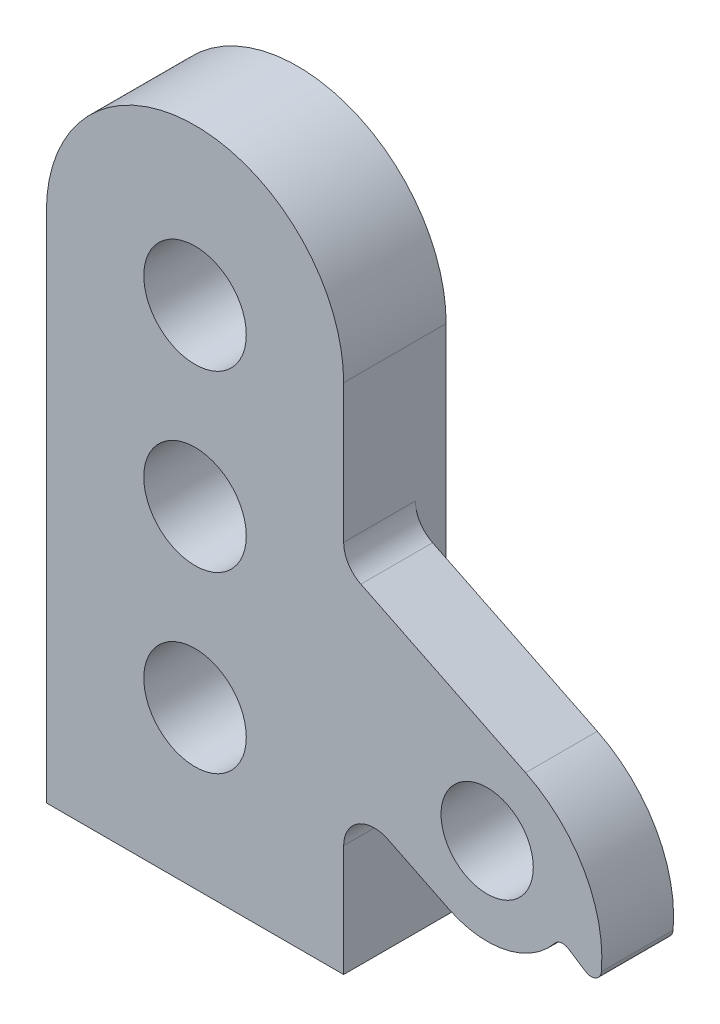
from build123d import *

# Parameters (mm, degrees)
ESQUISSE1_R             = 5
ESQUISSE1_R_2           = 4.5
BOSS_EXTRU_1_DEPTH      = 7
ESQUISSE4_R             = 5
BOSS_EXTRU_3_DEPTH      = 3
ESQUISSE5_W             = 29
ESQUISSE5_H             = 7
BOSS_EXTRU_4_DEPTH      = 8
ESQUISSE6_R             = 3
ENL_V_MAT_EXTRU_1_DEPTH = 65.5
ESQUISSE8_R             = 5
ENL_V_MAT_EXTRU_2_DEPTH = 19


with BuildPart() as part:
    # Esquisse1 → Boss.-Extru.1 (new body)
    with BuildSketch(Plane.XY):
        with BuildLine():
            Line((-14.5, -25), (14.5, -25))
            Line((14.5, -25), (14.5, -14.109086144))
            ThreePointArc((14.5, -14.109086144), (15.91383086, -11.562702933), (18.822711639, -11.416423165))
            Line((18.822711639, -11.416423165), (24.752317023, -14.329211775))
            ThreePointArc((24.752317023, -14.329211775), (30.322333643, -15.002355093), (35.098387692, -12.05829076))
            ThreePointArc((35.098387692, -12.05829076), (35.719225888, -11.700832999), (36.419839787, -11.850353167))
            Line((36.419839787, -11.850353167), (38.096489271, -12.940695548))
            ThreePointArc((38.096489271, -12.940695548), (39.079315926, -13.001513562), (39.637771245, -12.190480443))
            ThreePointArc((39.637771245, -12.190480443), (37.976265411, -4.485178535), (32.247682977, 0.929211775))
            Line((32.247682977, 0.929211775), (16.177288361, 8.823440709))
            ThreePointArc((16.177288361, 8.823440709), (14.953616789, 9.929934548), (14.5, 11.516103688))
            Line((14.5, 11.516103688), (14.5, 25))
            ThreePointArc((14.5, 25), (0, 39.5), (-14.5, 25))
            Line((-14.5, 25), (-14.5, -25))
        make_face()
        with Locations((0, 7.3)):
            Circle(ESQUISSE1_R, mode=Mode.SUBTRACT)
        with Locations((28.5, -6.7)):
            Circle(ESQUISSE1_R_2, mode=Mode.SUBTRACT)
    extrude(amount=BOSS_EXTRU_1_DEPTH)

    # Esquisse4 → Boss.-Extru.3 (add)
    with BuildSketch(Plane(origin=(0, 0, 0), x_dir=(-1, 0, 0), z_dir=(0, 0, -1))):
        with BuildLine():
            Line((14.5, 25), (14.5, -25))
            Line((14.5, -25), (-14.5, -25))
            Line((-14.5, -25), (-14.5, 25))
            ThreePointArc((-14.5, 25), (0, 39.5), (14.5, 25))
        make_face()
        with Locations((0, 7.3)):
            Circle(ESQUISSE4_R, mode=Mode.SUBTRACT)
    extrude(amount=BOSS_EXTRU_3_DEPTH)

    # Esquisse5 → Boss.-Extru.4 (add)
    with BuildSketch(Plane(origin=(0, 0, -3), x_dir=(-1, 0, 0), z_dir=(0, 0, -1))):
        with Locations((0, -21.5)):
            Rectangle(ESQUISSE5_W, ESQUISSE5_H)
    extrude(amount=BOSS_EXTRU_4_DEPTH)

    # Esquisse6 → Enlèv. mat.-Extru.1 (cut, through all)
    with BuildSketch(Plane.XZ.offset(25)):
        with Locations(Location((0, -7, 0), (0, 0, 270))):  # turned: the seam where the file's is
            Circle(ESQUISSE6_R)
    extrude(amount=-ENL_V_MAT_EXTRU_1_DEPTH, mode=Mode.SUBTRACT)

    # Esquisse8 → Enlèv. mat.-Extru.2 (cut, through all)
    with BuildSketch(Plane.XY.offset(7)):
        with Locations((0, -9.7)):
            Circle(ESQUISSE8_R)
        with Locations((0, 24.3)):
            Circle(ESQUISSE8_R)
    extrude(amount=-ENL_V_MAT_EXTRU_2_DEPTH, mode=Mode.SUBTRACT)


solid = part.part
